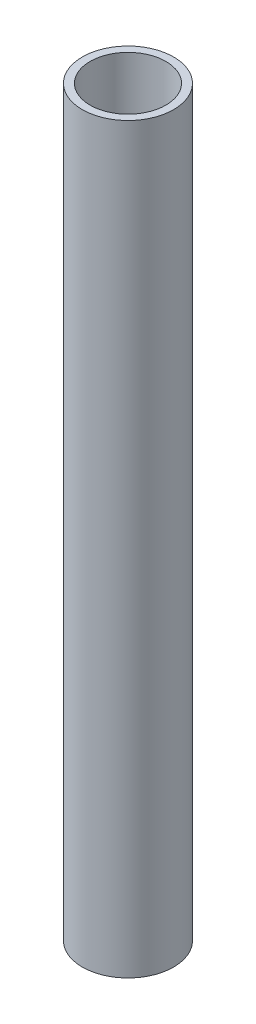
from build123d import *

# Parameters (mm, degrees)
SKETCH1_R           = 21.082
SKETCH1_R_2         = 17.5006
BOSS_EXTRUDE1_DEPTH = 342.9


with BuildPart() as part:
    # Sketch1 → Boss-Extrude1 (new body)
    with BuildSketch(Plane(origin=(0, 0, 0), x_dir=(1, 0, 0), z_dir=(0, 1, 0))):
        Circle(SKETCH1_R)
        Circle(SKETCH1_R_2, mode=Mode.SUBTRACT)
    extrude(amount=BOSS_EXTRUDE1_DEPTH)


solid = part.part
